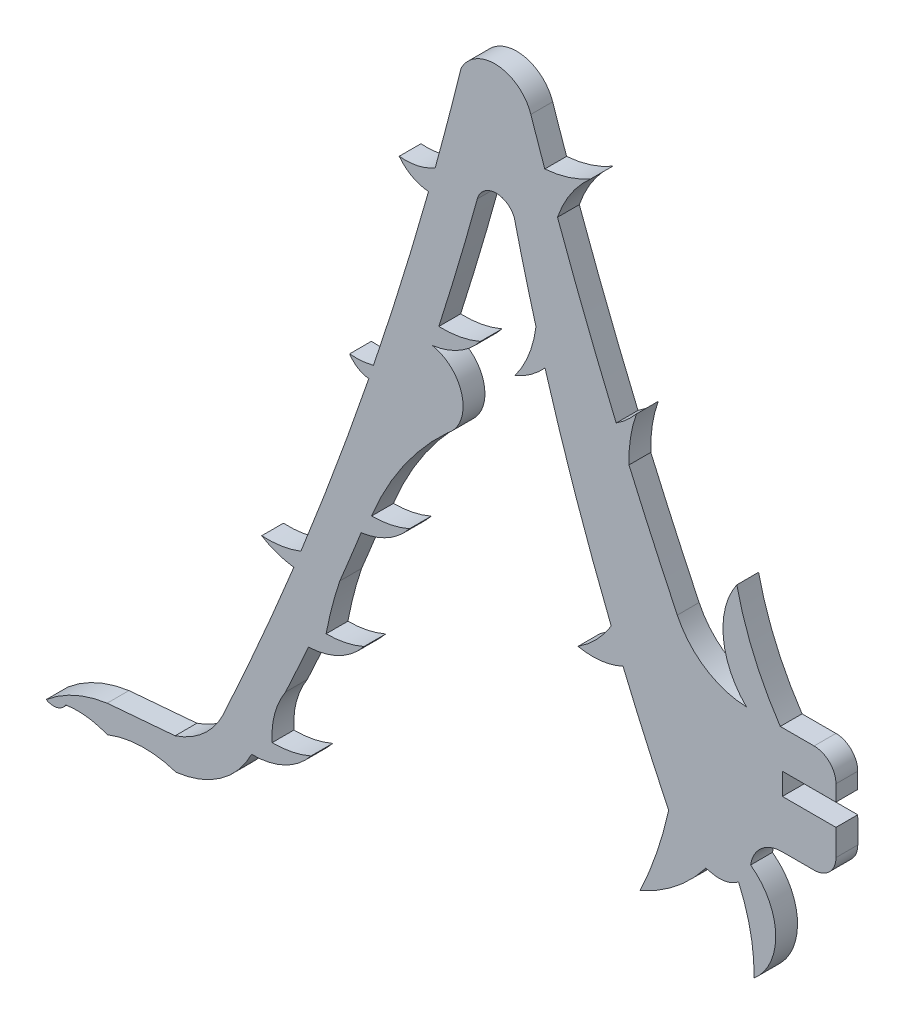
from build123d import *

# Parameters (mm, degrees)
BOSS_EXTRUDE1_DEPTH = 1.524


with BuildPart() as part:
    # Sketch1 → Boss-Extrude1 (new body)
    with BuildSketch(Plane.XY):
        with BuildLine():
            Line((23.841868496, -10.506949106), (26.068199276, -10.505871764))
            ThreePointArc((26.068199276, -10.505871764), (27.147715357, -10.058146709), (27.594179967, -8.978108726))
            Line((27.594179967, -8.978108726), (27.592193648, -7.149905424))
            Line((27.592193648, -7.149905424), (23.848771017, -7.149905424))
            Line((23.848771017, -7.149905424), (23.846783681, -5.623924224))
            Line((23.846783681, -5.623924224), (27.590206312, -5.623924224))
            Line((27.590206312, -5.623924224), (27.592193648, -4.513216426))
            ThreePointArc((27.592193648, -4.513216426), (27.145243923, -3.434184592), (26.06621194, -2.987235226))
            Line((26.06621194, -2.987235226), (23.700742448, -2.987731933))
            ThreePointArc((23.700742448, -2.987731933), (21.853763211, 0.396085968), (20.662942507, 4.062624108))
            ThreePointArc((20.662942507, 4.062624108), (19.722128306, 0.415432016), (21.335272956, -2.98822864))
            ThreePointArc((21.335272956, -2.98822864), (18.47901593, -2.097405096), (16.50646059, 0.152216254))
            ThreePointArc((16.50646059, 0.152216254), (14.785372428, 3.836585951), (13.130721746, 7.551267048))
            ThreePointArc((13.130721746, 7.551267048), (13.233622121, 9.252516805), (13.653748602, 10.904283424))
            ThreePointArc((13.653748602, 10.904283424), (12.99040582, 10.220702416), (12.234885694, 9.64061968))
            ThreePointArc((12.234885694, 9.64061968), (10.12080113, 14.817724102), (8.135197678, 20.045452354))
            ThreePointArc((8.135197678, 20.045452354), (9.07398957, 21.945137091), (10.469509483, 23.539708032))
            ThreePointArc((10.469509483, 23.539708032), (8.915709374, 22.846825686), (7.245789765, 22.521634627))
            ThreePointArc((7.245789765, 22.521634627), (6.75481808, 23.928653676), (6.273116214, 25.338873202))
            ThreePointArc((6.273116214, 25.338873202), (3.955147053, 27.136861073), (1.395527385, 25.703651887))
            ThreePointArc((1.395527385, 25.703651887), (0.515712233, 22.228862241), (-0.41145202, 18.766405854))
            ThreePointArc((-0.41145202, 18.766405854), (-1.622932108, 18.279372053), (-2.926572326, 18.205832225))
            ThreePointArc((-2.926572326, 18.205832225), (-2.022011476, 17.428802856), (-0.877304936, 17.094659314))
            ThreePointArc((-0.877304936, 17.094659314), (-2.723720739, 10.849649399), (-4.724433819, 4.652347782))
            ThreePointArc((-4.724433819, 4.652347782), (-5.553363062, 4.507568674), (-6.394830907, 4.511636389))
            ThreePointArc((-6.394830907, 4.511636389), (-5.816780919, 3.946754251), (-5.053213137, 3.681805461))
            ThreePointArc((-5.053213137, 3.681805461), (-7.342468518, -2.757262031), (-9.798511581, -9.134575953))
            ThreePointArc((-9.798511581, -9.134575953), (-11.146241899, -9.494732073), (-12.539374775, -9.567328436))
            ThreePointArc((-12.539374775, -9.567328436), (-11.456387472, -10.079926299), (-10.289959872, -10.353905718))
            ThreePointArc((-10.289959872, -10.353905718), (-12.696378355, -16.085978869), (-15.23781775, -21.759478522))
            ThreePointArc((-15.23781775, -21.759478522), (-16.613838722, -23.569338635), (-18.587158788, -24.698513227))
            Line((-18.587158788, -24.698513227), (-23.337428896, -25.097915233))
            ThreePointArc((-23.337428896, -25.097915233), (-25.600837555, -25.751570827), (-27.594180508, -27.00730498))
            ThreePointArc((-27.594180508, -27.00730498), (-26.834901197, -27.111562643), (-26.224288347, -26.648392395))
            ThreePointArc((-26.224288347, -26.648392395), (-24.749884123, -26.629116362), (-23.323298678, -27.002068563))
            ThreePointArc((-23.323298678, -27.002068563), (-20.933638176, -26.512638906), (-18.521050739, -26.872417397))
            ThreePointArc((-18.521050739, -26.872417397), (-15.408520041, -25.680590506), (-13.243289855, -23.146803434))
            ThreePointArc((-13.243289855, -23.146803434), (-10.939299547, -22.644411883), (-9.09502436, -21.174916172))
            ThreePointArc((-9.09502436, -21.174916172), (-10.422629625, -21.592521303), (-11.808160337, -21.723801278))
            ThreePointArc((-11.808160337, -21.723801278), (-11.629423676, -19.87808238), (-10.869125888, -18.186759728))
            ThreePointArc((-10.869125888, -18.186759728), (-10.06288258, -16.43139287), (-9.27114661, -14.669435086))
            ThreePointArc((-9.27114661, -14.669435086), (-7.116039845, -14.110620335), (-5.392996781, -12.70069775))
            ThreePointArc((-5.392996781, -12.70069775), (-6.685933272, -13.1111928), (-8.035353311, -13.249960648))
            ThreePointArc((-8.035353311, -13.249960648), (-7.62253261, -11.397230513), (-7.080348792, -9.578146516))
            ThreePointArc((-7.080348792, -9.578146516), (-6.326640496, -7.746057309), (-5.588458433, -5.90765738))
            ThreePointArc((-5.588458433, -5.90765738), (-3.713864907, -5.272651789), (-2.213006184, -3.982397519))
            ThreePointArc((-2.213006184, -3.982397519), (-3.505942675, -4.392892568), (-4.855362713, -4.531660417))
            ThreePointArc((-4.855362713, -4.531660417), (-2.628642535, -0.376345962), (0.470998143, 3.175716628))
            ThreePointArc((0.470998143, 3.175716628), (1.472273464, 5.892268907), (-0.603369584, 7.910662945))
            ThreePointArc((-0.603369584, 7.910662945), (1.254291962, 8.549045158), (2.741948703, 9.831743755))
            ThreePointArc((2.741948703, 9.831743755), (1.32183158, 9.396106351), (-0.159629899, 9.287550016))
            ThreePointArc((-0.159629899, 9.287550016), (1.231844903, 13.808566094), (2.531714491, 18.356766568))
            ThreePointArc((2.531714491, 18.356766568), (3.762130664, 19.35895724), (5.111523048, 18.523822342))
            ThreePointArc((5.111523048, 18.523822342), (5.841359999, 15.591441368), (6.629061504, 12.674071577))
            ThreePointArc((6.629061504, 12.674071577), (6.131201427, 10.721467417), (5.150999348, 8.960861967))
            ThreePointArc((5.150999348, 8.960861967), (6.286769778, 9.611384591), (7.260885888, 10.485599644))
            ThreePointArc((7.260885888, 10.485599644), (9.421271832, 3.777976775), (11.888720554, -2.82286929))
            ThreePointArc((11.888720554, -2.82286929), (10.862715973, -4.146724537), (9.567099571, -5.208165187))
            ThreePointArc((9.567099571, -5.208165187), (11.169841142, -5.279612135), (12.712295724, -4.838342295))
            ThreePointArc((12.712295724, -4.838342295), (14.260423663, -8.421579982), (15.8996033, -11.964090751))
            ThreePointArc((15.8996033, -11.964090751), (15.065930684, -14.956168746), (13.895117254, -17.833100562))
            ThreePointArc((13.895117254, -17.833100562), (16.426590022, -16.289885632), (18.495512952, -14.166345049))
            Line((18.495512952, -14.166345049), (19.168549545, -14.30256589))
            ThreePointArc((19.168549545, -14.30256589), (20.020311576, -14.238117294), (20.784861991, -13.857177873))
            ThreePointArc((20.784861991, -13.857177873), (21.617673082, -16.43239432), (21.871894835, -19.126960215))
            ThreePointArc((21.871894835, -19.126960215), (23.381897517, -15.709462317), (21.630181539, -12.409327303))
            ThreePointArc((21.630181539, -12.409327303), (22.378657332, -11.042665903), (23.841868496, -10.506949106))
        make_face()
    extrude(amount=BOSS_EXTRUDE1_DEPTH)


solid = part.part
